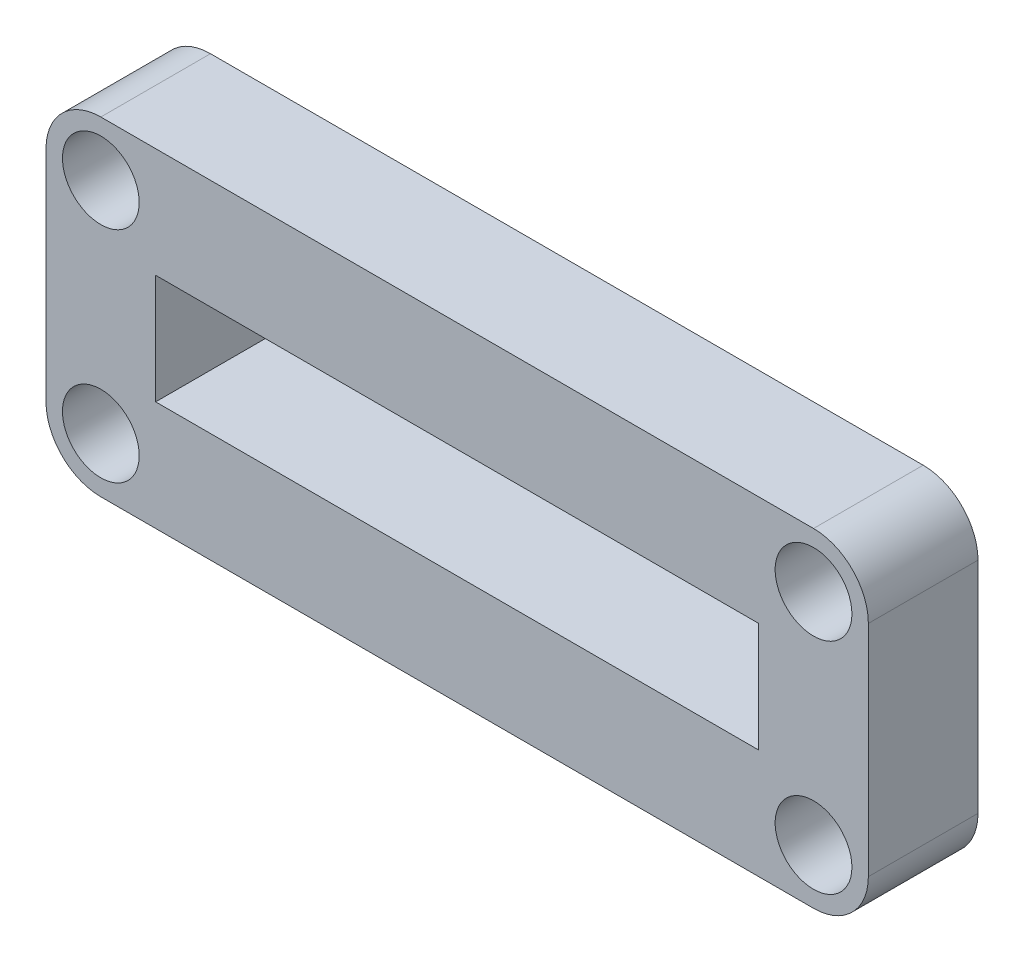
from build123d import *

# Parameters (mm, degrees)
SKETCH1_R           = 1.4
SKETCH1_W           = 20
SKETCH1_H           = 2
BOSS_EXTRUDE1_DEPTH = 7
SKETCH2_W           = 22
SKETCH2_H           = 4
SKETCH2_W_2         = 20
SKETCH2_H_2         = 2
CUT_EXTRUDE1_DEPTH  = 8.5
SKETCH3_R           = 39.79885979
CUT_EXTRUDE2_DEPTH  = 3


with BuildPart() as part:
    # Sketch1 → Boss-Extrude1 (new body)
    with BuildSketch(Plane.XY):
        with BuildLine():
            Line((-3, 0), (-3, -8))
            ThreePointArc((-3, -8), (-2.121320344, -10.121320344), (0, -11))
            Line((0, -11), (26, -11))
            ThreePointArc((26, -11), (28.121320344, -10.121320344), (29, -8))
            Line((29, -8), (29, 0))
            ThreePointArc((29, 0), (28.121320344, 2.121320344), (26, 3))
            Line((26, 3), (0, 3))
            ThreePointArc((0, 3), (-2.121320344, 2.121320344), (-3, 0))
        make_face()
        Circle(SKETCH1_R, mode=Mode.SUBTRACT)
        with Locations((0, -8)):
            Circle(SKETCH1_R, mode=Mode.SUBTRACT)
        with Locations((26, 0)):
            Circle(SKETCH1_R, mode=Mode.SUBTRACT)
        with Locations((26, -8)):
            Circle(SKETCH1_R, mode=Mode.SUBTRACT)
        with Locations((13, -4)):
            Rectangle(SKETCH1_W, SKETCH1_H, mode=Mode.SUBTRACT)
    extrude(amount=BOSS_EXTRUDE1_DEPTH)

    # Sketch2 → Cut-Extrude1 (cut)
    with BuildSketch(Plane.XY.offset(7)):
        with BuildLine():
            Line((26, 3), (0, 3))
            ThreePointArc((0, 3), (-2.121320344, 2.121320344), (-3, 0))
            Line((-3, 0), (-3, -8))
            ThreePointArc((-3, -8), (-2.121320344, -10.121320344), (0, -11))
            Line((0, -11), (26, -11))
            ThreePointArc((26, -11), (28.121320344, -10.121320344), (29, -8))
            Line((29, -8), (29, 0))
            ThreePointArc((29, 0), (28.121320344, 2.121320344), (26, 3))
        make_face()
        with BuildLine():
            Line((-2, -8), (-2, 0))
            ThreePointArc((-2, 0), (-1.414213562, 1.414213562), (0, 2))
            Line((0, 2), (26, 2))
            ThreePointArc((26, 2), (27.414213562, 1.414213562), (28, 0))
            Line((28, 0), (28, -8))
            ThreePointArc((28, -8), (27.414213562, -9.414213562), (26, -10))
            Line((26, -10), (0, -10))
            ThreePointArc((0, -10), (-1.414213562, -9.414213562), (-2, -8))
        make_face(mode=Mode.SUBTRACT)
        with Locations((13, -4)):
            Rectangle(SKETCH2_W, SKETCH2_H)
        with Locations((13, -4)):
            Rectangle(SKETCH2_W_2, SKETCH2_H_2, mode=Mode.SUBTRACT)
    extrude(amount=-CUT_EXTRUDE1_DEPTH, mode=Mode.SUBTRACT)

    # Sketch3 → Cut-Extrude2 (cut)
    with BuildSketch(Plane.XY.offset(7)):
        with Locations((0, 0.278776736)):
            Circle(SKETCH3_R)
    extrude(amount=-CUT_EXTRUDE2_DEPTH, mode=Mode.SUBTRACT)


solid = part.part
